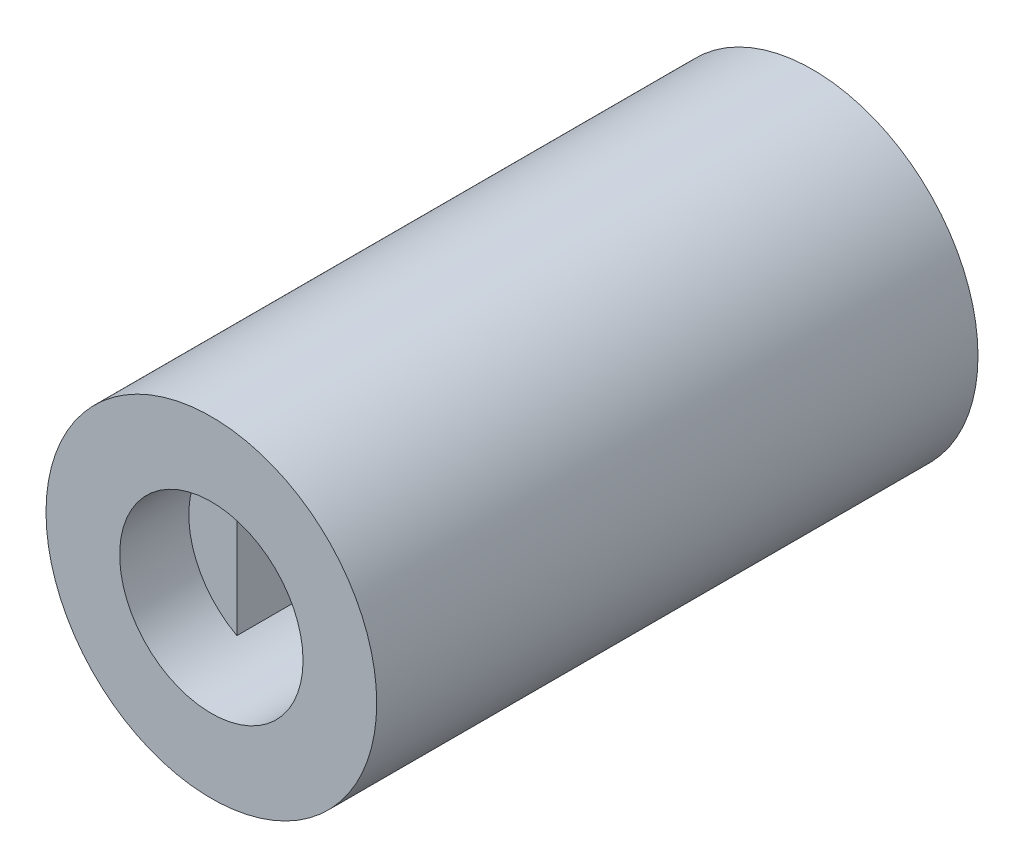
from build123d import *

# Parameters (mm, degrees)
SKETCH1_R           = 5.5
BOSS_EXTRUDE1_DEPTH = 20
CUT_EXTRUDE1_DEPTH  = 12
CUT_EXTRUDE2_DEPTH  = 7.8
SKETCH4_R           = 3.05
CUT_EXTRUDE3_DEPTH  = 2.3


with BuildPart() as part:
    # Sketch1 → Boss-Extrude1 (new body)
    with BuildSketch(Plane.XY):
        Circle(SKETCH1_R)
    extrude(amount=BOSS_EXTRUDE1_DEPTH)

    # Sketch2 → Cut-Extrude1 (cut)
    with BuildSketch(Plane.XY.offset(20)):
        with BuildLine():
            ThreePointArc((-1.45, -2.683281573), (3.05, 0), (-1.45, 2.683281573))
            Line((-1.45, 2.683281573), (-1.45, -2.683281573))
        make_face()
    extrude(amount=-CUT_EXTRUDE1_DEPTH, mode=Mode.SUBTRACT)

    # Sketch3 → Cut-Extrude2 (cut)
    with BuildSketch(Plane(origin=(0, 0, 0), x_dir=(-1, 0, 0), z_dir=(0, 0, -1))):
        with BuildLine():
            Line((2.3, -2.078460969), (2.3, 2.078460969))
            ThreePointArc((2.3, 2.078460969), (0, 3.1), (-2.3, 2.078460969))
            Line((-2.3, 2.078460969), (-2.3, -2.078460969))
            ThreePointArc((-2.3, -2.078460969), (0, -3.1), (2.3, -2.078460969))
        make_face()
    extrude(amount=-CUT_EXTRUDE2_DEPTH, mode=Mode.SUBTRACT)

    # Sketch4 → Cut-Extrude3 (cut)
    with BuildSketch(Plane.XY.offset(20)):
        Circle(SKETCH4_R)
    extrude(amount=-CUT_EXTRUDE3_DEPTH, mode=Mode.SUBTRACT)


solid = part.part
